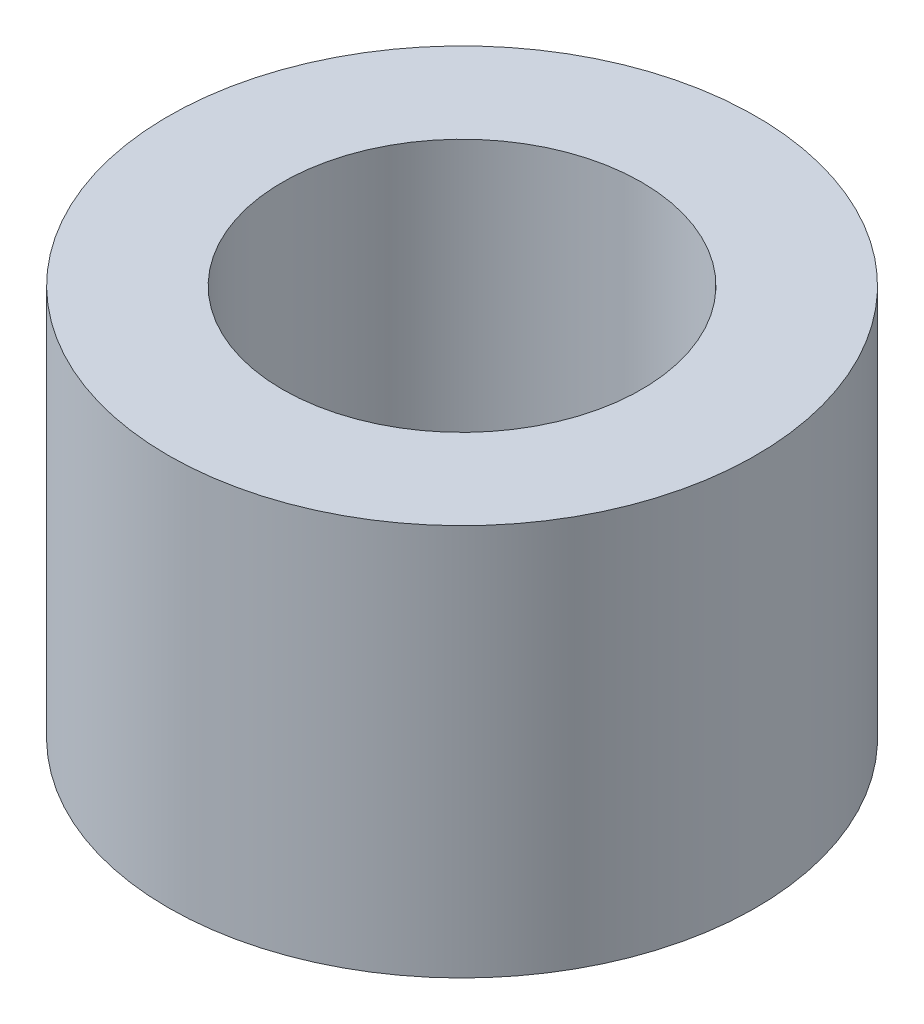
from build123d import *

# Parameters (mm, degrees)
SKETCH1_R           = 2.249999945
SKETCH1_R_2         = 1.375000044
BOSS_EXTRUDE1_DEPTH = 3


with BuildPart() as part:
    # Sketch1 → Boss-Extrude1 (new body)
    with BuildSketch(Plane(origin=(0, 0, 0), x_dir=(1, 0, 0), z_dir=(0, 1, 0))):
        Circle(SKETCH1_R)
        Circle(SKETCH1_R_2, mode=Mode.SUBTRACT)
    extrude(amount=BOSS_EXTRUDE1_DEPTH)


solid = part.part
